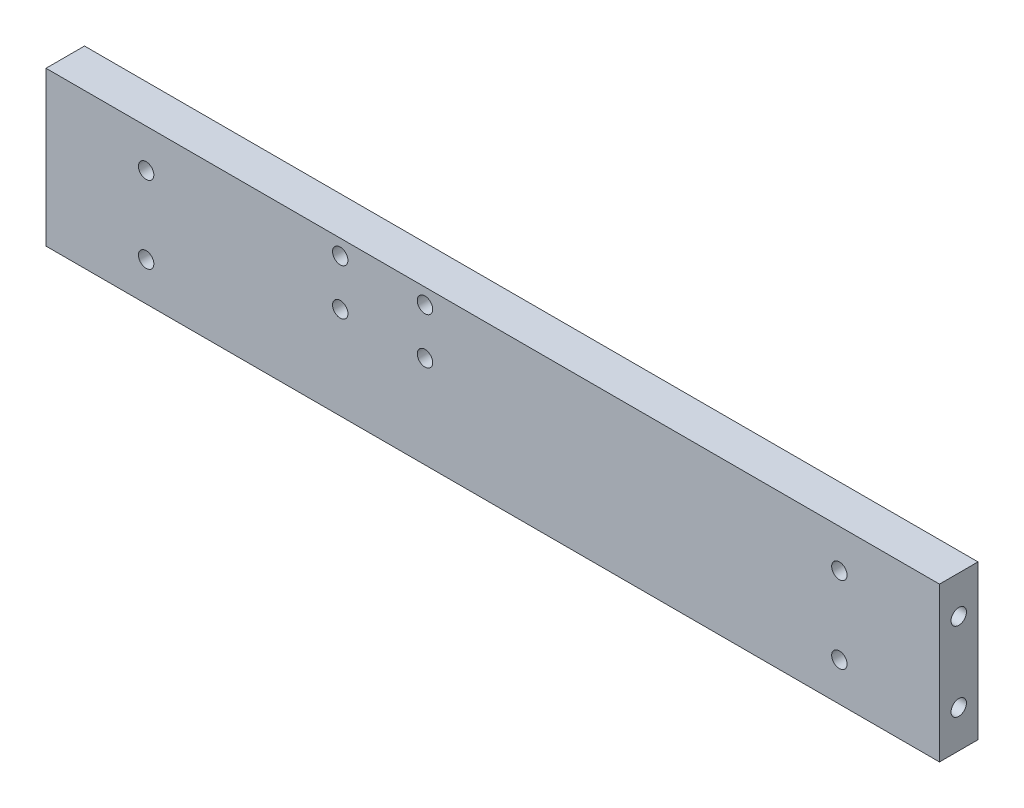
from build123d import *

# Parameters (mm, degrees)
SKETCH1_W           = 116
SKETCH1_H           = 20
BOSS_EXTRUDE2_DEPTH = 5
SKETCH4_R           = 1
CUT_EXTRUDE1_DEPTH  = 10
SKETCH6_R           = 1
CUT_EXTRUDE2_DEPTH  = 5
SKETCH7_R           = 1
CUT_EXTRUDE3_DEPTH  = 6
SKETCH8_R           = 1
CUT_EXTRUDE4_DEPTH  = 6


with BuildPart() as part:
    # Sketch1 → Boss-Extrude2 (new body)
    with BuildSketch(Plane.XY):
        Rectangle(SKETCH1_W, SKETCH1_H)
    extrude(amount=BOSS_EXTRUDE2_DEPTH)

    # Sketch4 → Cut-Extrude1 (cut)
    with BuildSketch(Plane(origin=(58, 0, 0), x_dir=(0, 0, -1), z_dir=(1, 0, 0))):
        with Locations((-2.5, -5.12)):
            Circle(SKETCH4_R)
        with Locations((-2.5, 5.12)):
            Circle(SKETCH4_R)
    extrude(amount=-CUT_EXTRUDE1_DEPTH, mode=Mode.SUBTRACT)

    # Sketch6 → Cut-Extrude2 (cut)
    with BuildSketch(Plane.ZY.offset(58)):
        with Locations((2.5, 5)):
            Circle(SKETCH6_R)
        with Locations((2.5, -5)):
            Circle(SKETCH6_R)
    extrude(amount=-CUT_EXTRUDE2_DEPTH, mode=Mode.SUBTRACT)

    # Sketch7 → Cut-Extrude3 (cut, through all)
    with BuildSketch(Plane(origin=(0, 0, 0), x_dir=(-1, 0, 0), z_dir=(0, 0, -1))):
        with Locations((-45, 5)):
            Circle(SKETCH7_R)
        with Locations((-45, -5)):
            Circle(SKETCH7_R)
        with Locations((45, 5)):
            Circle(SKETCH7_R)
        with Locations((45, -5)):
            Circle(SKETCH7_R)
    extrude(amount=-CUT_EXTRUDE3_DEPTH, mode=Mode.SUBTRACT)

    # Sketch8 → Cut-Extrude4 (cut, through all)
    with BuildSketch(Plane(origin=(0, 0, 0), x_dir=(-1, 0, 0), z_dir=(0, 0, -1))):
        with Locations((8.8, 8)):
            Circle(SKETCH8_R)
        with Locations((8.8, 2)):
            Circle(SKETCH8_R)
        with Locations((19.8, 2)):
            Circle(SKETCH8_R)
        with Locations((19.8, 8)):
            Circle(SKETCH8_R)
    extrude(amount=-CUT_EXTRUDE4_DEPTH, mode=Mode.SUBTRACT)


solid = part.part
